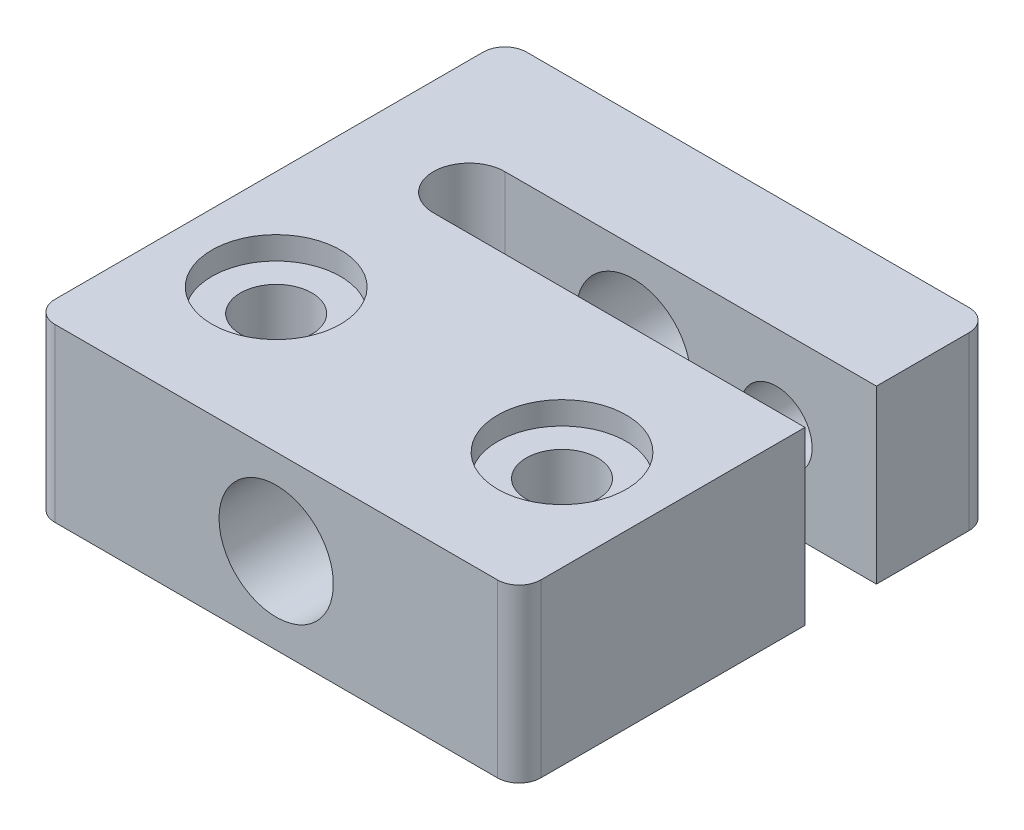
from build123d import *

# Parameters (mm, degrees)
SKETCH1_R           = 2.5
BOSS_EXTRUDE1_DEPTH = 12
SKETCH2_R           = 4.5
CUT_EXTRUDE1_DEPTH  = 1.6
CUT_EXTRUDE2_DEPTH  = 4.97
SKETCH4_R           = 4
CUT_EXTRUDE3_DEPTH  = 34
CUT_EXTRUDE4_REACH  = 35
SKETCH5_R           = 2.5


with BuildPart() as part:
    # Sketch1 → Boss-Extrude1 (new body)
    with BuildSketch(Plane(origin=(0, 0, 0), x_dir=(1, 0, 0), z_dir=(0, 1, 0))):
        with BuildLine():
            Line((-15.48, 0), (15.48, 0))
            ThreePointArc((15.48, 0), (16.554802307, 0.445197693), (17, 1.52))
            Line((17, 1.52), (17, 20))
            Line((17, 20), (-9, 20))
            ThreePointArc((-9, 20), (-11.5, 22.5), (-9, 25))
            Line((-9, 25), (17, 25))
            Line((17, 25), (17, 31.48))
            ThreePointArc((17, 31.48), (16.554802307, 32.554802307), (15.48, 33))
            Line((15.48, 33), (-15.48, 33))
            ThreePointArc((-15.48, 33), (-16.554802307, 32.554802307), (-17, 31.48))
            Line((-17, 31.48), (-17, 1.52))
            ThreePointArc((-17, 1.52), (-16.554802307, 0.445197693), (-15.48, 0))
        make_face()
        with Locations((-10, 10)):
            Circle(SKETCH1_R, mode=Mode.SUBTRACT)
        with Locations((10, 10)):
            Circle(SKETCH1_R, mode=Mode.SUBTRACT)
    extrude(amount=BOSS_EXTRUDE1_DEPTH)

    # Sketch2 → Cut-Extrude1 (cut)
    with BuildSketch(Plane(origin=(0, 12, 0), x_dir=(1, 0, 0), z_dir=(0, 1, 0))):
        with Locations((-10, 10)):
            Circle(SKETCH2_R)
        with Locations((10, 10)):
            Circle(SKETCH2_R)
    extrude(amount=-CUT_EXTRUDE1_DEPTH, mode=Mode.SUBTRACT)

    # Sketch3 → Cut-Extrude2 (cut)
    with BuildSketch(Plane.XZ):
        Polygon((6, -7.690598923), (6, -12.309401077), (10, -14.618802154), (14, -12.309401077), (14, -7.690598923), (10, -5.381197846), align=None)
        Polygon((-14, -12.309401077), (-10, -14.618802154), (-6, -12.309401077), (-6, -7.690598923), (-10, -5.381197846), (-14, -7.690598923), align=None)
    extrude(amount=-CUT_EXTRUDE2_DEPTH, mode=Mode.SUBTRACT)

    # Sketch4 → Cut-Extrude3 (cut, through all)
    with BuildSketch(Plane(origin=(0, 0, -33), x_dir=(-1, 0, 0), z_dir=(0, 0, -1))):
        with Locations((0, 6)):
            Circle(SKETCH4_R)
    extrude(amount=-CUT_EXTRUDE3_DEPTH, mode=Mode.SUBTRACT)

    # Sketch5 → Cut-Extrude4 (cut, up to next)
    with BuildSketch(Plane(origin=(0, 0, -33), x_dir=(-1, 0, 0), z_dir=(0, 0, -1)), mode=Mode.PRIVATE) as cut_extrude4_sk1:
        with Locations((-10, 6)):
            Circle(SKETCH5_R)
    cut_extrude4_tool1 = extrude(cut_extrude4_sk1.sketch, amount=-CUT_EXTRUDE4_REACH, mode=Mode.PRIVATE) & part.part
    add(cut_extrude4_tool1.solids().sort_by_distance((10, 6, -33))[0], mode=Mode.SUBTRACT)


solid = part.part
